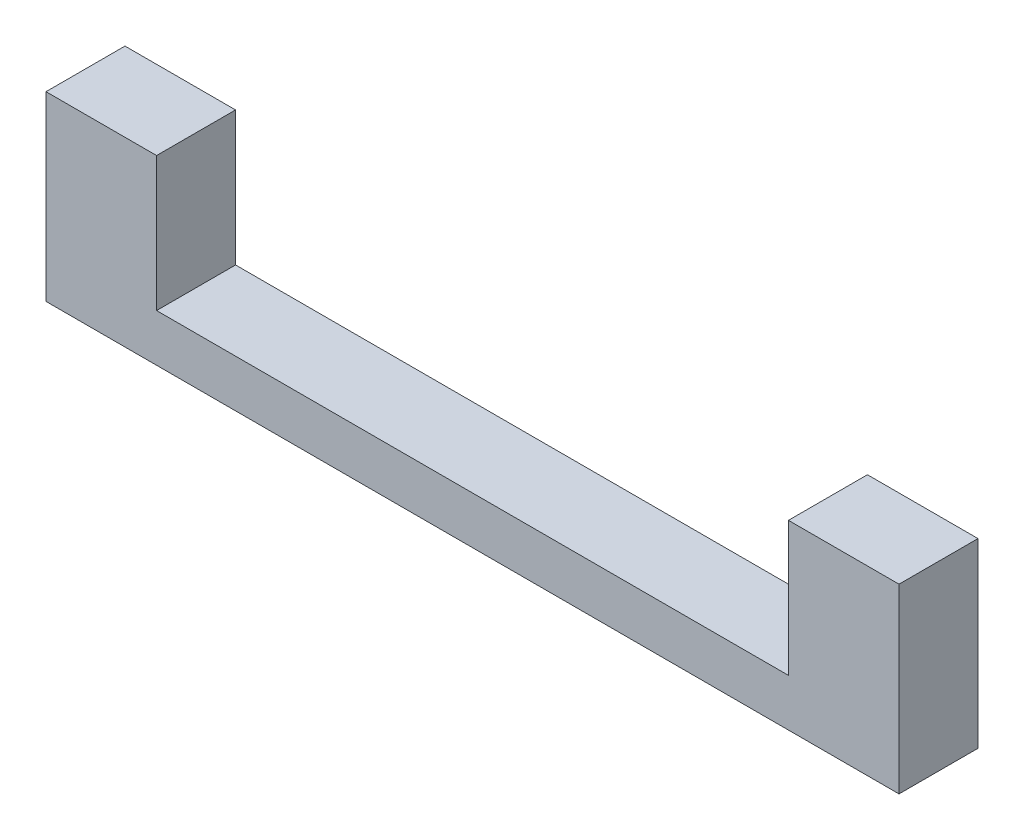
from build123d import *

# Parameters (mm, degrees)
SKETCH1_W           = 8.5
SKETCH1_H           = 8.5
BOSS_EXTRUDE1_DEPTH = 5
SKETCH2_W           = 8.5
SKETCH2_H           = 8.5
BOSS_EXTRUDE2_DEPTH = 2
SKETCH3_R           = 1.5
CUT_EXTRUDE1_DEPTH  = 2
SKETCH4_W           = 54
SKETCH4_H           = 8.5
BOSS_EXTRUDE3_DEPTH = 3
SKETCH5_W           = 7
SKETCH5_H           = 8.5
BOSS_EXTRUDE4_DEPTH = 8.5
SKETCH8_R           = 1.5
BOSS_EXTRUDE5_DEPTH = 2.5
SKETCH9_R           = 1.5
BOSS_EXTRUDE6_DEPTH = 2.5
SKETCH10_W          = 8.5
SKETCH10_H          = 8.5
BOSS_EXTRUDE7_DEPTH = 1
CUT_EXTRUDE4_DEPTH  = 0.5
CUT_EXTRUDE5_DEPTH  = 0.5
SKETCH14_W          = 8.5
SKETCH14_H          = 8.5
BOSS_EXTRUDE8_DEPTH = 8
SKETCH15_W          = 8.5
SKETCH15_H          = 8.5
CUT_EXTRUDE6_DEPTH  = 1
SKETCH16_W          = 54
SKETCH16_H          = 3.5
CUT_EXTRUDE7_DEPTH  = 15
SKETCH17_W          = 5
SKETCH17_H          = 8.5
BOSS_EXTRUDE9_DEPTH = 7


with BuildPart() as part:
    # Sketch1 → Boss-Extrude1 (new body)
    with BuildSketch(Plane(origin=(0, 0, 0), x_dir=(0, 0, -1), z_dir=(1, 0, 0))):
        Rectangle(SKETCH1_W, SKETCH1_H)
        Polygon((1.705, 2.953146627), (-1.705, 2.953146627), (-3.41, 0), (-1.705, -2.953146627), (1.705, -2.953146627), (3.41, 0), align=None, mode=Mode.SUBTRACT)
    extrude(amount=BOSS_EXTRUDE1_DEPTH)

    # Sketch2 → Boss-Extrude2 (add)
    with BuildSketch(Plane.ZY):
        Rectangle(SKETCH2_W, SKETCH2_H)
    extrude(amount=BOSS_EXTRUDE2_DEPTH)

    # Sketch3 → Cut-Extrude1 (cut)
    with BuildSketch(Plane(origin=(0, 0, 0), x_dir=(0, 0, -1), z_dir=(1, 0, 0))):
        Circle(SKETCH3_R)
    extrude(amount=-CUT_EXTRUDE1_DEPTH, mode=Mode.SUBTRACT)

    # Sketch4 → Boss-Extrude3 (add)
    with BuildSketch(Plane.XZ.offset(4.25)):
        with Locations((25, 0)):
            Rectangle(SKETCH4_W, SKETCH4_H)
    extrude(amount=BOSS_EXTRUDE3_DEPTH)

    # Sketch5 → Boss-Extrude4 (add)
    with BuildSketch(Plane(origin=(0, -4.25, 0), x_dir=(1, 0, 0), z_dir=(0, 1, 0))):
        with Locations((48.5, 0)):
            Rectangle(SKETCH5_W, SKETCH5_H)
    extrude(amount=BOSS_EXTRUDE4_DEPTH)

    # Sketch8 → Boss-Extrude5 (add)
    with BuildSketch(Plane(origin=(0, 0, 0), x_dir=(0, 0, -1), z_dir=(1, 0, 0))):
        Polygon((-1.705, 2.953146627), (-3.41, 0), (-1.705, -2.953146627), (1.705, -2.953146627), (3.41, 0), (1.705, 2.953146627), align=None)
        Circle(SKETCH8_R, mode=Mode.SUBTRACT)
    extrude(amount=BOSS_EXTRUDE5_DEPTH)

    # Sketch9 → Boss-Extrude6 (add)
    with BuildSketch(Plane.ZY.offset(-50)):
        Polygon((3.41, 0), (1.705, 2.953146627), (-1.705, 2.953146627), (-3.41, 0), (-1.705, -2.953146627), (1.705, -2.953146627), align=None)
        with Locations(Location((0, 0, 0), (0, 0, 180))):
            Circle(SKETCH9_R, mode=Mode.SUBTRACT)
    extrude(amount=BOSS_EXTRUDE6_DEPTH)

    # Sketch10 → Boss-Extrude7 (add)
    with BuildSketch(Plane(origin=(5, 0, 0), x_dir=(0, 0, -1), z_dir=(1, 0, 0))):
        Rectangle(SKETCH10_W, SKETCH10_H)
        Polygon((3.41, 0), (1.705, 2.953146627), (-1.705, 2.953146627), (-3.41, 0), (-1.705, -2.953146627), (1.705, -2.953146627), align=None, mode=Mode.SUBTRACT)
    extrude(amount=BOSS_EXTRUDE7_DEPTH)

    # Sketch12 → Cut-Extrude4 (cut)
    with BuildSketch(Plane(origin=(2.5, 0, 0), x_dir=(0, 0, -1), z_dir=(1, 0, 0))):
        Polygon((1.705, -2.953146627), (3.41, 0), (1.705, 2.953146627), (-1.705, 2.953146627), (-3.41, 0), (-1.705, -2.953146627), align=None)
    extrude(amount=-CUT_EXTRUDE4_DEPTH, mode=Mode.SUBTRACT)

    # Sketch13 → Cut-Extrude5 (cut)
    with BuildSketch(Plane.ZY.offset(-47.5)):
        Polygon((1.705, 2.953146627), (-1.705, 2.953146627), (-3.41, 0), (-1.705, -2.953146627), (1.705, -2.953146627), (3.41, 0), align=None)
    extrude(amount=-CUT_EXTRUDE5_DEPTH, mode=Mode.SUBTRACT)

    # Sketch14 → Boss-Extrude8 (add)
    with BuildSketch(Plane(origin=(6, 0, 0), x_dir=(0, 0, -1), z_dir=(1, 0, 0))):
        Rectangle(SKETCH14_W, SKETCH14_H)
    extrude(amount=-BOSS_EXTRUDE8_DEPTH)

    # Sketch15 → Cut-Extrude6 (cut)
    with BuildSketch(Plane(origin=(6, 0, 0), x_dir=(0, 0, -1), z_dir=(1, 0, 0))):
        Rectangle(SKETCH15_W, SKETCH15_H)
    extrude(amount=-CUT_EXTRUDE6_DEPTH, mode=Mode.SUBTRACT)

    # Sketch16 → Cut-Extrude7 (cut)
    with BuildSketch(Plane(origin=(0, 4.25, 0), x_dir=(1, 0, 0), z_dir=(0, 1, 0))):
        with Locations((25, 2.5)):
            Rectangle(SKETCH16_W, SKETCH16_H)
    extrude(amount=-CUT_EXTRUDE7_DEPTH, mode=Mode.SUBTRACT)

    # Sketch17 → Boss-Extrude9 (add)
    with BuildSketch(Plane.ZY.offset(-45)):
        with Locations((1.75, 0)):
            Rectangle(SKETCH17_W, SKETCH17_H)
    extrude(amount=-BOSS_EXTRUDE9_DEPTH)


solid = part.part
